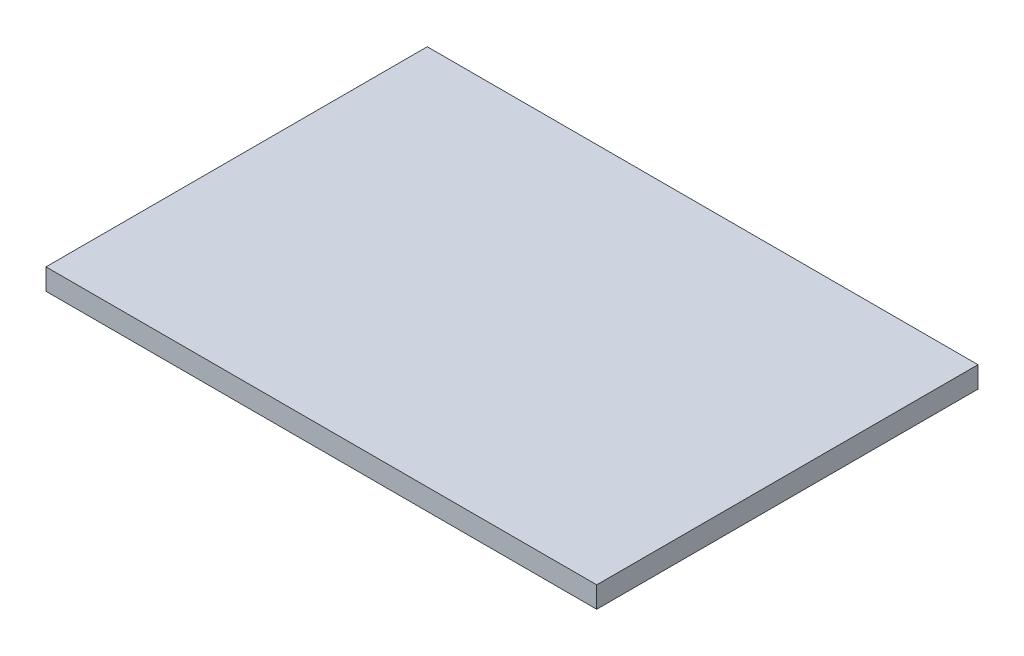
from build123d import *

# Parameters (mm, degrees)
SKETCH1_W           = 26
SKETCH1_H           = 18
BOSS_EXTRUDE1_DEPTH = 1


with BuildPart() as part:
    # Sketch1 → Boss-Extrude1 (new body)
    with BuildSketch(Plane(origin=(0, 0, 0), x_dir=(1, 0, 0), z_dir=(0, 1, 0))):
        Rectangle(SKETCH1_W, SKETCH1_H)
    extrude(amount=BOSS_EXTRUDE1_DEPTH)


solid = part.part
